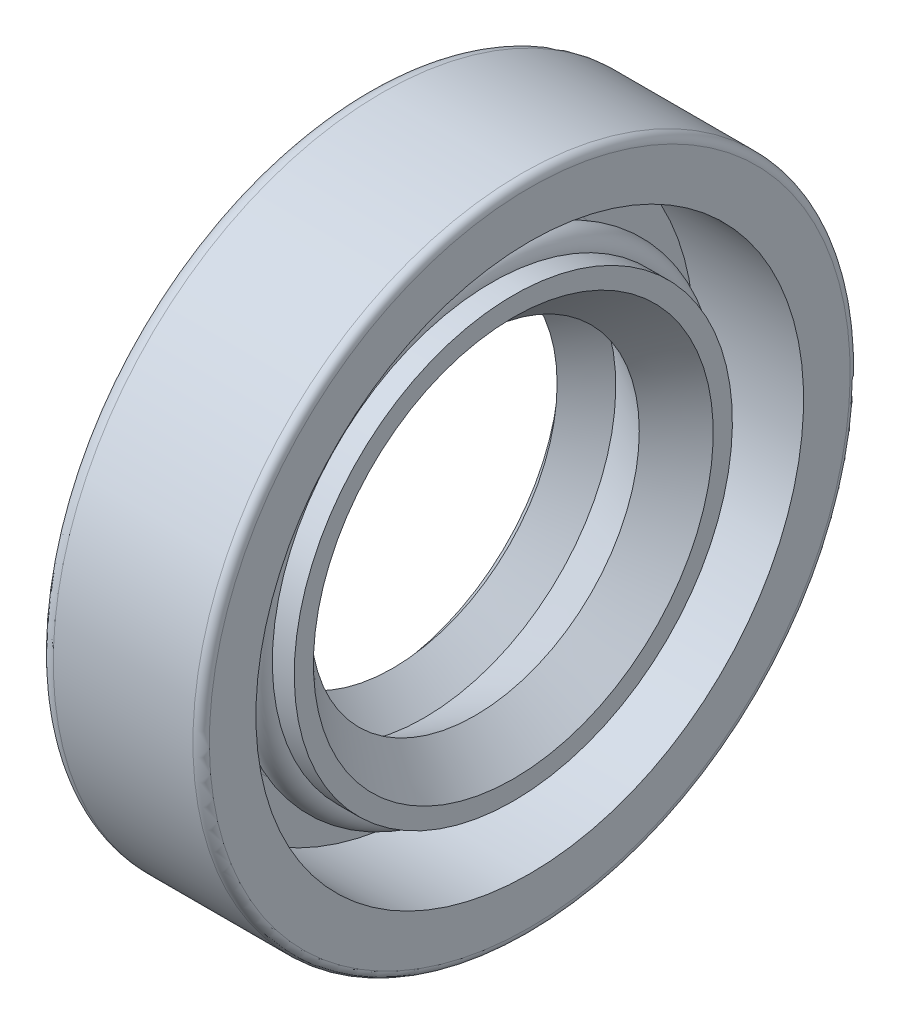
from build123d import *

# Parameters (mm, degrees)
SKETCH2_R = 0.635


with BuildPart() as part:
    # Sketch1 → Revolve1 (revolve)
    with BuildSketch(Plane.XY):
        with BuildLine():
            Line((0, 10.583333333), (0.1984375, 10.583333333))
            Line((0.1984375, 10.583333333), (0.1984375, 8.466666667))
            Line((0.1984375, 8.466666667), (0, 8.466666667))
            Line((0, 8.466666667), (0, 7.9375))
            Line((0, 7.9375), (1.058333333, 7.408333333))
            Line((1.058333333, 7.408333333), (0.53376973, 6.948811386))
            Line((0.53376973, 6.948811386), (1.058333333, 6.35))
            Line((1.058333333, 6.35), (2.266465286, 7.408333333))
            Line((2.266465286, 7.408333333), (4.233333333, 6.35))
            Line((4.233333333, 6.35), (5.715, 7.725833333))
            Line((5.715, 7.725833333), (5.715, 8.466666667))
            Line((5.715, 8.466666667), (4.868333333, 8.466666667))
            ThreePointArc((4.868333333, 8.466666667), (4.233333333, 7.831666667), (3.598333333, 8.466666667))
            Line((3.598333333, 8.466666667), (2.434166667, 8.466666667))
            ThreePointArc((2.434166667, 8.466666667), (2.209660264, 8.559660264), (2.116666667, 8.784166667))
            Line((2.116666667, 8.784166667), (2.116666667, 10.583333333))
            Line((2.116666667, 10.583333333), (6.35, 10.583333333))
            Line((6.35, 10.583333333), (6.35, 12.3825))
            ThreePointArc((6.35, 12.3825), (6.257006403, 12.607006403), (6.0325, 12.7))
            Line((6.0325, 12.7), (0.635, 12.7))
            ThreePointArc((0.635, 12.7), (0.185987194, 12.514012806), (0, 12.065))
            Line((0, 12.065), (0, 10.583333333))
        make_face()
    revolve(axis=Axis((6.35, 0, 0), (-1, 0, 0)))


with BuildPart() as body_2:
    # Sketch2 → Revolve2 (revolve)
    with BuildSketch(Plane.XY):
        with Locations((4.233333333, 8.466666667)):
            Circle(SKETCH2_R)
    revolve(axis=Axis((0, 0, 0), (1, 0, 0)))


solid = Compound([part.part, body_2.part])
